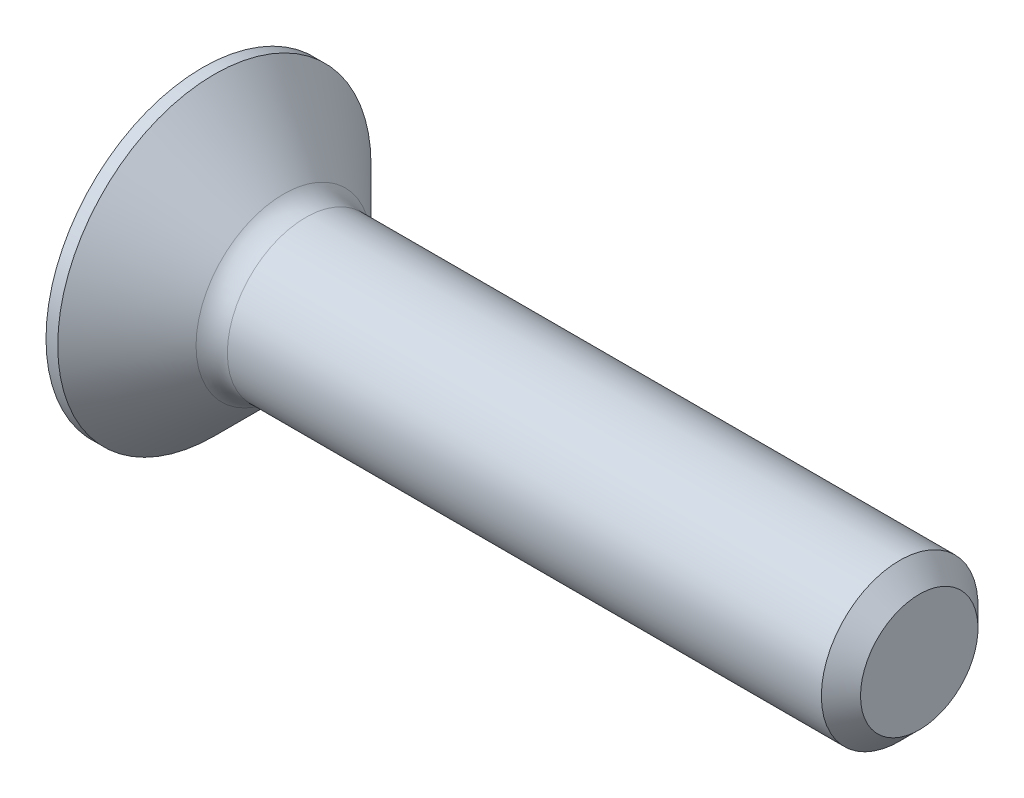
from build123d import *

# Parameters (mm, degrees)
FILLET1_R   = 0.8
HEX_2_DEPTH = 5.6


with BuildPart() as part:
    # BodySke → BaseBody (revolve)
    with BuildSketch(Plane.XY):
        Polygon((0, 0), (0, 4), (0.3, 4), (2.3, 2), (17.8, 2), (18.3, 1.5), (18.3, 0), align=None)
    revolve(axis=Axis((0, 0, 0), (1, 0, 0)))

    # Fillet1
    fillet1_edges = [part.edges().sort_by_distance(p)[0] for p in [
        (2.3, -2, 0),
    ]]
    fillet(fillet1_edges, radius=FILLET1_R)

    # Sketch3 → Hex 2 (cut)
    with BuildSketch(Plane.ZY):
        Polygon((-1.25, -0.721687836), (-1.25, 0.721687836), (0, 1.443375673), (1.25, 0.721687836), (1.25, -0.721687836), (0, -1.443375673), align=None)
    extrude(amount=-HEX_2_DEPTH, mode=Mode.SUBTRACT)


solid = part.part
